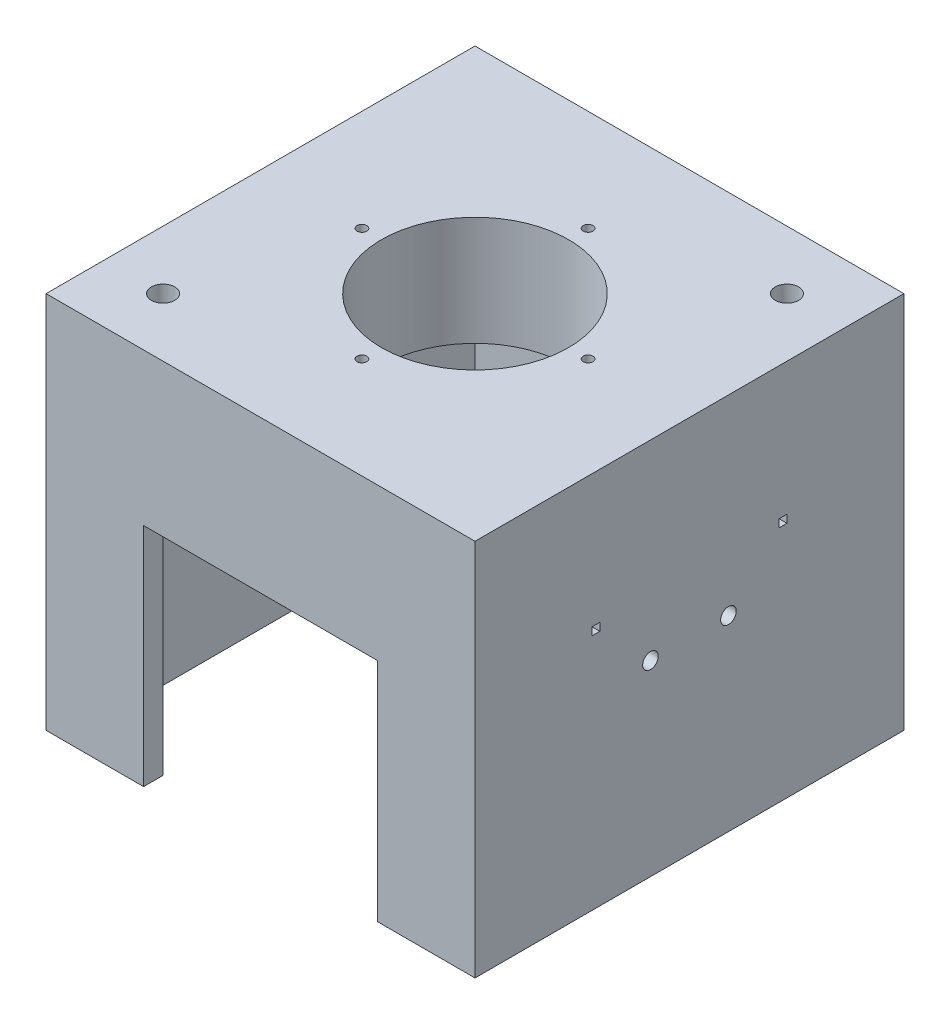
from build123d import *

# Parameters (mm, degrees)
SKETCH2_W                = 110
SKETCH2_H                = 110
SKETCH2_W_2              = 100
SKETCH2_H_2              = 100
BOSS_EXTRUDE1_DEPTH      = 89
SKETCH3_W                = 110
SKETCH3_H                = 110
BOSS_EXTRUDE2_DEPTH      = 8
CUT_EXTRUDE1_REACH       = 112
SKETCH6_W                = 60
SKETCH6_H                = 58
SKETCH9_W                = 110
SKETCH9_H                = 110
BOSS_EXTRUDE3_DEPTH      = 3
CUT_EXTRUDE2_REACH       = 63
SKETCH10_R               = 7.5
BOSS_EXTRUDE4_DEPTH      = 1.5
BOSS_EXTRUDE5_DEPTH      = 1.5
SKETCH14_R               = 3
CUT_EXTRUDE3_DEPTH       = 73
SKETCH15_W               = 2
SKETCH15_H               = 2
CUT_EXTRUDE4_DEPTH       = 113
CUT_EXTRUDE4_DEPTH_BACK  = 13
CUT_EXTRUDE5_REACH       = 63
SKETCH16_R               = 2.5
SKETCH17_R               = 14
SKETCH17_R_2             = 11
BOSS_EXTRUDE6_DEPTH      = 7
CUT_EXTRUDE8_REACH       = 7
SKETCH20_R               = 2
SKETCH18_R               = 2
CUT_EXTRUDE6_DEPTH       = 73.5
CUT_EXTRUDE7_REACH       = 63
SKETCH19_R               = 2
SKETCH21_R               = 24
SKETCH21_R_2             = 21
BOSS_EXTRUDE7_DEPTH      = 5
CUT_EXTRUDE9_REACH       = 46
SKETCH23_W               = 100
SKETCH23_H               = 100
SKETCH24_W               = 100
SKETCH24_H               = 100
BOSS_EXTRUDE8_DEPTH      = 20
SKETCH25_R               = 24
CUT_EXTRUDE10_DEPTH      = 10
CUT_EXTRUDE10_DEPTH_BACK = 26
SKETCH26_R               = 3
CUT_EXTRUDE11_DEPTH      = 26
M3_TAPPED_HOLE1_D        = 2.5
M3_TAPPED_HOLE1_DEPTH    = 6.748924226
M3_TAPPED_HOLE1_TIP      = 0.751075774
M3_TAPPED_HOLE2_D        = 2.5
M3_TAPPED_HOLE2_DEPTH    = 6.748924226
M3_TAPPED_HOLE2_TIP      = 0.751075774


with BuildPart() as part:
    # Sketch2 → Boss-Extrude1 (new body)
    with BuildSketch(Plane(origin=(0, 0, 0), x_dir=(1, 0, 0), z_dir=(0, 1, 0))):
        Rectangle(SKETCH2_W, SKETCH2_H)
        Rectangle(SKETCH2_W_2, SKETCH2_H_2, mode=Mode.SUBTRACT)
    extrude(amount=BOSS_EXTRUDE1_DEPTH)

    # Sketch3 → Boss-Extrude2 (add)
    with BuildSketch(Plane(origin=(0, 89, 0), x_dir=(1, 0, 0), z_dir=(0, 1, 0))):
        Rectangle(SKETCH3_W, SKETCH3_H)
    extrude(amount=BOSS_EXTRUDE2_DEPTH)

    # Sketch6 → Cut-Extrude1 (cut, up to next)
    with BuildSketch(Plane.XY.offset(55), mode=Mode.PRIVATE) as cut_extrude1_sk1:
        with Locations((0, 29)):
            Rectangle(SKETCH6_W, SKETCH6_H)
    cut_extrude1_tool1 = extrude(cut_extrude1_sk1.sketch, amount=-CUT_EXTRUDE1_REACH, mode=Mode.PRIVATE) & part.part
    add(cut_extrude1_tool1.solids().sort_by_distance((0, 29, 55))[0], mode=Mode.SUBTRACT)

    # Sketch8 → Cut-Revolve1 (revolve, cut)
    with BuildSketch(Plane.XY):
        Polygon((0, 97), (-21, 97), (-21, 92.5), (-16.2, 92.5), (-16.2, 88.5), (0, 88.5), align=None)
    revolve(axis=Axis((0, 0, 0), (0, 1, 0)), mode=Mode.SUBTRACT)

    # Sketch9 → Boss-Extrude3 (add)
    with BuildSketch(Plane.XZ.offset(-58)):
        Rectangle(SKETCH9_W, SKETCH9_H)
    extrude(amount=-BOSS_EXTRUDE3_DEPTH)

    # Sketch10 → Cut-Extrude2 (cut, up to next)
    with BuildSketch(Plane(origin=(0, 61, 0), x_dir=(1, 0, 0), z_dir=(0, 1, 0)), mode=Mode.PRIVATE) as cut_extrude2_sk1:
        Circle(SKETCH10_R)
    cut_extrude2_tool1 = extrude(cut_extrude2_sk1.sketch, amount=-CUT_EXTRUDE2_REACH, mode=Mode.PRIVATE) & part.part
    add(cut_extrude2_tool1.solids().sort_by_distance((0, 61, 0))[0], mode=Mode.SUBTRACT)

    # Sketch11 → Boss-Extrude4 (add, symmetric)
    with BuildSketch(Plane.XY):
        Polygon((-50, 89), (-35, 89), (-50, 69), align=None)
    boss_extrude4 = extrude(amount=BOSS_EXTRUDE4_DEPTH, both=True)

    # Mirror1: Boss-Extrude4 across plane
    add(boss_extrude4.mirror(Plane(origin=(0, 0, 0), x_dir=(0, 0, 1), z_dir=(1, 0, 0))))

    # Sketch12 → Boss-Extrude5 (add, symmetric)
    with BuildSketch(Plane(origin=(0, 0, 0), x_dir=(0, 0, -1), z_dir=(1, 0, 0))):
        Polygon((-35, 89), (-50, 89), (-50, 69), align=None)
    boss_extrude5 = extrude(amount=BOSS_EXTRUDE5_DEPTH, both=True)

    # Mirror2: Boss-Extrude5 across plane
    add(boss_extrude5.mirror(Plane.XY))

    # Sketch14 → Cut-Extrude3 (cut)
    with BuildSketch(Plane(origin=(0, 97, 0), x_dir=(1, 0, 0), z_dir=(0, 1, 0))):
        with Locations((40, 40)):
            Circle(SKETCH14_R)
        with Locations((-40, -40)):
            Circle(SKETCH14_R)
    extrude(amount=-CUT_EXTRUDE3_DEPTH, mode=Mode.SUBTRACT)

    # Sketch15 → Cut-Extrude4 (cut, two sides)
    with BuildSketch(Plane(origin=(-50, 0, 0), x_dir=(0, 0, -1), z_dir=(1, 0, 0))) as cut_extrude4_sk:
        with Locations((-24, 62)):
            Rectangle(SKETCH15_W, SKETCH15_H)
        with Locations((24, 62)):
            Rectangle(SKETCH15_W, SKETCH15_H)
    extrude(amount=CUT_EXTRUDE4_DEPTH, mode=Mode.SUBTRACT)
    extrude(cut_extrude4_sk.sketch, amount=-CUT_EXTRUDE4_DEPTH_BACK, mode=Mode.SUBTRACT)

    # Sketch16 → Cut-Extrude5 (cut, up to next)
    with BuildSketch(Plane(origin=(0, 61, 0), x_dir=(1, 0, 0), z_dir=(0, 1, 0)), mode=Mode.PRIVATE) as cut_extrude5_sk1:
        with Locations((-13.5, 13.5)):
            Circle(SKETCH16_R)
    cut_extrude5_tool1 = extrude(cut_extrude5_sk1.sketch, amount=-CUT_EXTRUDE5_REACH, mode=Mode.PRIVATE) & part.part
    add(cut_extrude5_tool1.solids().sort_by_distance((-13.5, 61, -13.5))[0], mode=Mode.SUBTRACT)
    # Sketch16 → Cut-Extrude5 (cut, up to next)
    with BuildSketch(Plane(origin=(0, 61, 0), x_dir=(1, 0, 0), z_dir=(0, 1, 0)), mode=Mode.PRIVATE) as cut_extrude5_sk2:
        with Locations((-13.5, -36)):
            Circle(SKETCH16_R)
    cut_extrude5_tool2 = extrude(cut_extrude5_sk2.sketch, amount=-CUT_EXTRUDE5_REACH, mode=Mode.PRIVATE) & part.part
    add(cut_extrude5_tool2.solids().sort_by_distance((-13.5, 61, 36))[0], mode=Mode.SUBTRACT)
    # Sketch16 → Cut-Extrude5 (cut, up to next)
    with BuildSketch(Plane(origin=(0, 61, 0), x_dir=(1, 0, 0), z_dir=(0, 1, 0)), mode=Mode.PRIVATE) as cut_extrude5_sk3:
        with Locations((13.5, -36)):
            Circle(SKETCH16_R)
    cut_extrude5_tool3 = extrude(cut_extrude5_sk3.sketch, amount=-CUT_EXTRUDE5_REACH, mode=Mode.PRIVATE) & part.part
    add(cut_extrude5_tool3.solids().sort_by_distance((13.5, 61, 36))[0], mode=Mode.SUBTRACT)
    # Sketch16 → Cut-Extrude5 (cut, up to next)
    with BuildSketch(Plane(origin=(0, 61, 0), x_dir=(1, 0, 0), z_dir=(0, 1, 0)), mode=Mode.PRIVATE) as cut_extrude5_sk4:
        with Locations((13.5, 13.5)):
            Circle(SKETCH16_R)
    cut_extrude5_tool4 = extrude(cut_extrude5_sk4.sketch, amount=-CUT_EXTRUDE5_REACH, mode=Mode.PRIVATE) & part.part
    add(cut_extrude5_tool4.solids().sort_by_distance((13.5, 61, -13.5))[0], mode=Mode.SUBTRACT)

    # Sketch17 → Boss-Extrude6 (add)
    with BuildSketch(Plane(origin=(0, 61, 0), x_dir=(1, 0, 0), z_dir=(0, 1, 0))):
        Circle(SKETCH17_R)
        Circle(SKETCH17_R_2, mode=Mode.SUBTRACT)
    extrude(amount=BOSS_EXTRUDE6_DEPTH)

    # Sketch20 → Cut-Extrude8 (cut, up to next)
    with BuildSketch(Plane.XY.offset(-50), mode=Mode.PRIVATE) as cut_extrude8_sk1:
        with Locations((10, 48)):
            Circle(SKETCH20_R)
    cut_extrude8_tool1 = extrude(cut_extrude8_sk1.sketch, amount=-CUT_EXTRUDE8_REACH, mode=Mode.PRIVATE) & part.part
    add(cut_extrude8_tool1.solids().sort_by_distance((10, 48, -50))[0], mode=Mode.SUBTRACT)
    # Sketch20 → Cut-Extrude8 (cut, up to next)
    with BuildSketch(Plane.XY.offset(-50), mode=Mode.PRIVATE) as cut_extrude8_sk2:
        with Locations((-10, 48)):
            Circle(SKETCH20_R)
    cut_extrude8_tool2 = extrude(cut_extrude8_sk2.sketch, amount=-CUT_EXTRUDE8_REACH, mode=Mode.PRIVATE) & part.part
    add(cut_extrude8_tool2.solids().sort_by_distance((-10, 48, -50))[0], mode=Mode.SUBTRACT)

    # Sketch18 → Cut-Extrude6 (cut, symmetric)
    with BuildSketch(Plane(origin=(0, 0, 0), x_dir=(0, 0, -1), z_dir=(1, 0, 0))):
        with Locations((10, 48)):
            Circle(SKETCH18_R)
        with Locations((-10, 48)):
            Circle(SKETCH18_R)
    extrude(amount=CUT_EXTRUDE6_DEPTH, both=True, mode=Mode.SUBTRACT)

    # Sketch19 → Cut-Extrude7 (cut, up to next)
    with BuildSketch(Plane(origin=(0, 61, 0), x_dir=(1, 0, 0), z_dir=(0, 1, 0)), mode=Mode.PRIVATE) as cut_extrude7_sk1:
        with Locations((40, 10)):
            Circle(SKETCH19_R)
    cut_extrude7_tool1 = extrude(cut_extrude7_sk1.sketch, amount=-CUT_EXTRUDE7_REACH, mode=Mode.PRIVATE) & part.part
    add(cut_extrude7_tool1.solids().sort_by_distance((40, 61, -10))[0], mode=Mode.SUBTRACT)
    # Sketch19 → Cut-Extrude7 (cut, up to next)
    with BuildSketch(Plane(origin=(0, 61, 0), x_dir=(1, 0, 0), z_dir=(0, 1, 0)), mode=Mode.PRIVATE) as cut_extrude7_sk2:
        with Locations((40, -10)):
            Circle(SKETCH19_R)
    cut_extrude7_tool2 = extrude(cut_extrude7_sk2.sketch, amount=-CUT_EXTRUDE7_REACH, mode=Mode.PRIVATE) & part.part
    add(cut_extrude7_tool2.solids().sort_by_distance((40, 61, 10))[0], mode=Mode.SUBTRACT)
    # Sketch19 → Cut-Extrude7 (cut, up to next)
    with BuildSketch(Plane(origin=(0, 61, 0), x_dir=(1, 0, 0), z_dir=(0, 1, 0)), mode=Mode.PRIVATE) as cut_extrude7_sk3:
        with Locations((-40, -10)):
            Circle(SKETCH19_R)
    cut_extrude7_tool3 = extrude(cut_extrude7_sk3.sketch, amount=-CUT_EXTRUDE7_REACH, mode=Mode.PRIVATE) & part.part
    add(cut_extrude7_tool3.solids().sort_by_distance((-40, 61, 10))[0], mode=Mode.SUBTRACT)
    # Sketch19 → Cut-Extrude7 (cut, up to next)
    with BuildSketch(Plane(origin=(0, 61, 0), x_dir=(1, 0, 0), z_dir=(0, 1, 0)), mode=Mode.PRIVATE) as cut_extrude7_sk4:
        with Locations((-40, 10)):
            Circle(SKETCH19_R)
    cut_extrude7_tool4 = extrude(cut_extrude7_sk4.sketch, amount=-CUT_EXTRUDE7_REACH, mode=Mode.PRIVATE) & part.part
    add(cut_extrude7_tool4.solids().sort_by_distance((-40, 61, -10))[0], mode=Mode.SUBTRACT)
    # Sketch19 → Cut-Extrude7 (cut, up to next)
    with BuildSketch(Plane(origin=(0, 61, 0), x_dir=(1, 0, 0), z_dir=(0, 1, 0)), mode=Mode.PRIVATE) as cut_extrude7_sk5:
        with Locations((10, 40)):
            Circle(SKETCH19_R)
    cut_extrude7_tool5 = extrude(cut_extrude7_sk5.sketch, amount=-CUT_EXTRUDE7_REACH, mode=Mode.PRIVATE) & part.part
    add(cut_extrude7_tool5.solids().sort_by_distance((10, 61, -40))[0], mode=Mode.SUBTRACT)
    # Sketch19 → Cut-Extrude7 (cut, up to next)
    with BuildSketch(Plane(origin=(0, 61, 0), x_dir=(1, 0, 0), z_dir=(0, 1, 0)), mode=Mode.PRIVATE) as cut_extrude7_sk6:
        with Locations((-10, 40)):
            Circle(SKETCH19_R)
    cut_extrude7_tool6 = extrude(cut_extrude7_sk6.sketch, amount=-CUT_EXTRUDE7_REACH, mode=Mode.PRIVATE) & part.part
    add(cut_extrude7_tool6.solids().sort_by_distance((-10, 61, -40))[0], mode=Mode.SUBTRACT)

    # Sketch21 → Boss-Extrude7 (add)
    with BuildSketch(Plane(origin=(0, 97, 0), x_dir=(1, 0, 0), z_dir=(0, 1, 0))):
        Circle(SKETCH21_R)
        Circle(SKETCH21_R_2, mode=Mode.SUBTRACT)
    extrude(amount=BOSS_EXTRUDE7_DEPTH)

    # Sketch23 → Cut-Extrude9 (cut, up to next)
    with BuildSketch(Plane.XZ.offset(-58), mode=Mode.PRIVATE) as cut_extrude9_sk1:
        Rectangle(SKETCH23_W, SKETCH23_H)
    cut_extrude9_tool1 = extrude(cut_extrude9_sk1.sketch, amount=-CUT_EXTRUDE9_REACH, mode=Mode.PRIVATE) & part.part
    add(cut_extrude9_tool1.solids().sort_by_distance((0, 58, 0))[0], mode=Mode.SUBTRACT)

    # Sketch24 → Boss-Extrude8 (add)
    with BuildSketch(Plane.XZ.offset(-89)):
        Rectangle(SKETCH24_W, SKETCH24_H)
    extrude(amount=BOSS_EXTRUDE8_DEPTH)

    # Sketch25 → Cut-Extrude10 (cut, two sides)
    with BuildSketch(Plane(origin=(0, 92.5, 0), x_dir=(1, 0, 0), z_dir=(0, 1, 0))) as cut_extrude10_sk:
        Circle(SKETCH25_R)
    extrude(amount=CUT_EXTRUDE10_DEPTH, mode=Mode.SUBTRACT)
    extrude(cut_extrude10_sk.sketch, amount=-CUT_EXTRUDE10_DEPTH_BACK, mode=Mode.SUBTRACT)

    # Sketch26 → Cut-Extrude11 (cut)
    with BuildSketch(Plane(origin=(0, 89, 0), x_dir=(1, 0, 0), z_dir=(0, 1, 0))):
        with Locations((-40, -40)):
            Circle(SKETCH26_R)
        with Locations((40, 40)):
            Circle(SKETCH26_R)
    extrude(amount=-CUT_EXTRUDE11_DEPTH, mode=Mode.SUBTRACT)

    # M3 Tapped Hole1
    with Locations(Plane(origin=(-29, 97, 0), x_dir=(0, 0, 1), z_dir=(0, 1, 0))):
        with Locations((0, 0), (29, 29), (0, 58), (-29, 29)):
            Hole(M3_TAPPED_HOLE1_D / 2, depth=M3_TAPPED_HOLE1_DEPTH)
            with Locations((0, 0, -(M3_TAPPED_HOLE1_DEPTH + M3_TAPPED_HOLE1_TIP / 2))):  # 118° drill point
                Cone(0, M3_TAPPED_HOLE1_D / 2, M3_TAPPED_HOLE1_TIP, mode=Mode.SUBTRACT)

    # M3 Tapped Hole2
    with Locations(Plane(origin=(0, 69, 0), x_dir=(-1, 0, 0), z_dir=(0, -1, 0))):
        with Locations((0, -29), (29, 0), (0, 29), (-29, 0)):
            Hole(M3_TAPPED_HOLE2_D / 2, depth=M3_TAPPED_HOLE2_DEPTH)
            with Locations((0, 0, -(M3_TAPPED_HOLE2_DEPTH + M3_TAPPED_HOLE2_TIP / 2))):  # 118° drill point
                Cone(0, M3_TAPPED_HOLE2_D / 2, M3_TAPPED_HOLE2_TIP, mode=Mode.SUBTRACT)


solid = part.part
